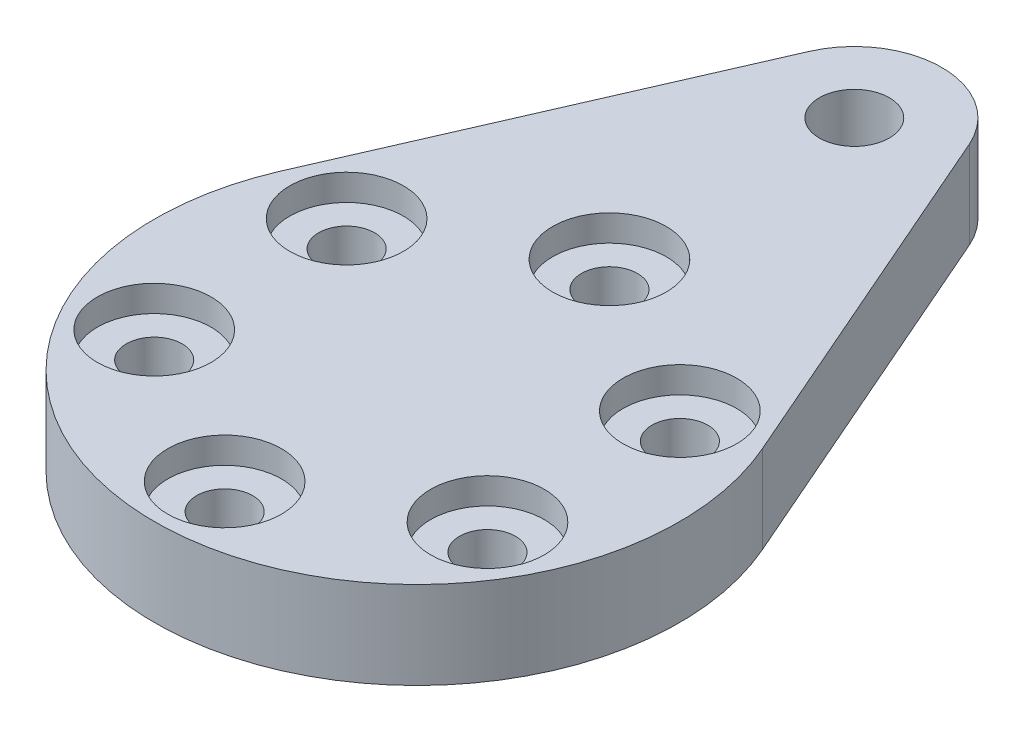
from build123d import *

# Parameters (mm, degrees)
SKETCH4_R           = 2
SKETCH4_R_2         = 1.6
BOSS_EXTRUDE1_DEPTH = 5
SKETCH6_R           = 3.25
CUT_EXTRUDE1_DEPTH  = 1.5


with BuildPart() as part:
    # Sketch4 → Boss-Extrude1 (new body)
    with BuildSketch(Plane(origin=(0, 0, 0), x_dir=(1, 0, 0), z_dir=(0, 1, 0))):
        with BuildLine():
            Line((13.747727085, 6), (4.582575695, 27))
            ThreePointArc((4.582575695, 27), (0, 30), (-4.582575695, 27))
            Line((-4.582575695, 27), (-13.747727085, 6))
            ThreePointArc((-13.747727085, 6), (0, -15), (13.747727085, 6))
        make_face()
        with Locations((0, 25)):
            Circle(SKETCH4_R, mode=Mode.SUBTRACT)
        with Locations((0, 11)):
            Circle(SKETCH4_R_2, mode=Mode.SUBTRACT)
        with Locations((-9.526279442, -5.5)):
            Circle(SKETCH4_R_2, mode=Mode.SUBTRACT)
        with Locations((-9.526279442, 5.5)):
            Circle(SKETCH4_R_2, mode=Mode.SUBTRACT)
        with Locations((0, -11)):
            Circle(SKETCH4_R_2, mode=Mode.SUBTRACT)
        with Locations((9.526279442, -5.5)):
            Circle(SKETCH4_R_2, mode=Mode.SUBTRACT)
        with Locations((9.526279442, 5.5)):
            Circle(SKETCH4_R_2, mode=Mode.SUBTRACT)
    extrude(amount=BOSS_EXTRUDE1_DEPTH)

    # Sketch6 → Cut-Extrude1 (cut)
    with BuildSketch(Plane(origin=(0, 5, 0), x_dir=(1, 0, 0), z_dir=(0, 1, 0))):
        with Locations((0, 11)):
            Circle(SKETCH6_R)
        with Locations((9.526279442, 5.5)):
            Circle(SKETCH6_R)
        with Locations((9.526279442, -5.5)):
            Circle(SKETCH6_R)
        with Locations((0, -11)):
            Circle(SKETCH6_R)
        with Locations((-9.526279442, -5.5)):
            Circle(SKETCH6_R)
        with Locations((-9.526279442, 5.5)):
            Circle(SKETCH6_R)
    extrude(amount=-CUT_EXTRUDE1_DEPTH, mode=Mode.SUBTRACT)


solid = part.part
